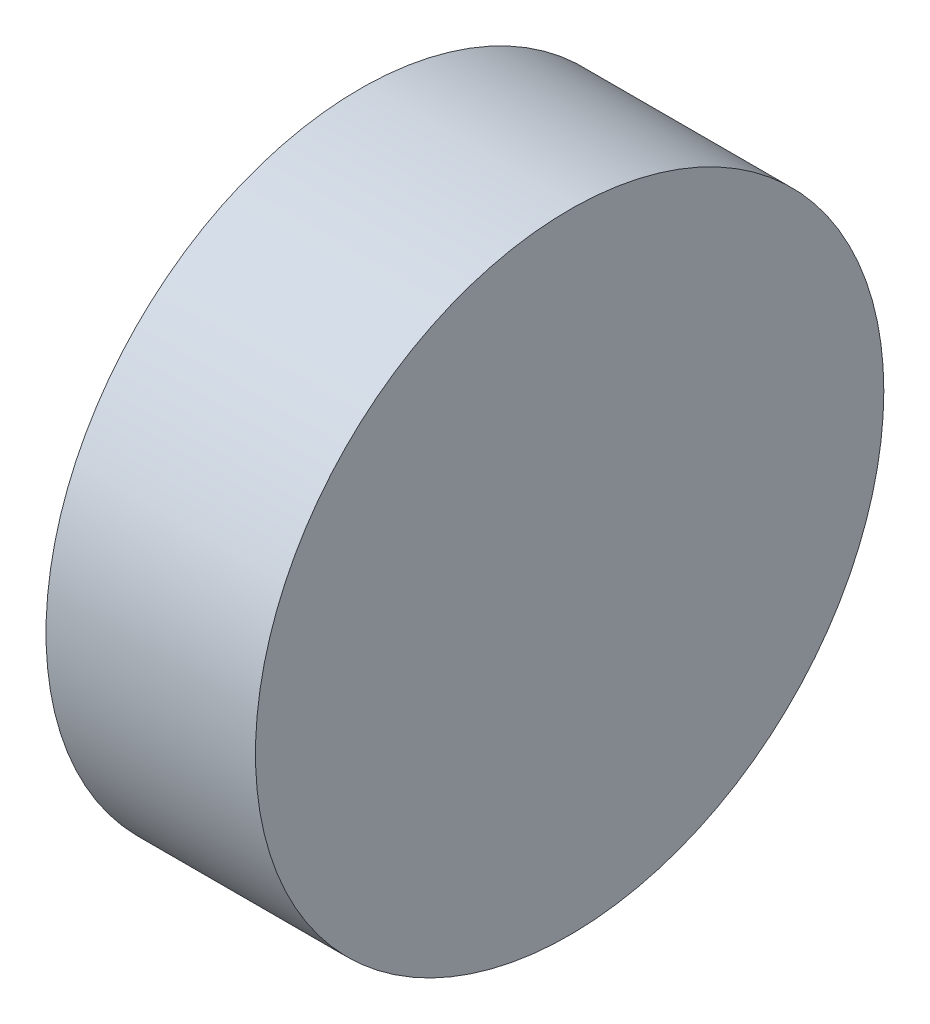
from build123d import *

# Parameters (mm, degrees)
SKETCH1_R           = 76.2
BOSS_EXTRUDE1_DEPTH = 50.8


with BuildPart() as part:
    # Sketch1 → Boss-Extrude1 (new body)
    with BuildSketch(Plane(origin=(0, 0, 0), x_dir=(0, 0, -1), z_dir=(1, 0, 0))):
        Circle(SKETCH1_R)
    extrude(amount=BOSS_EXTRUDE1_DEPTH)


solid = part.part
